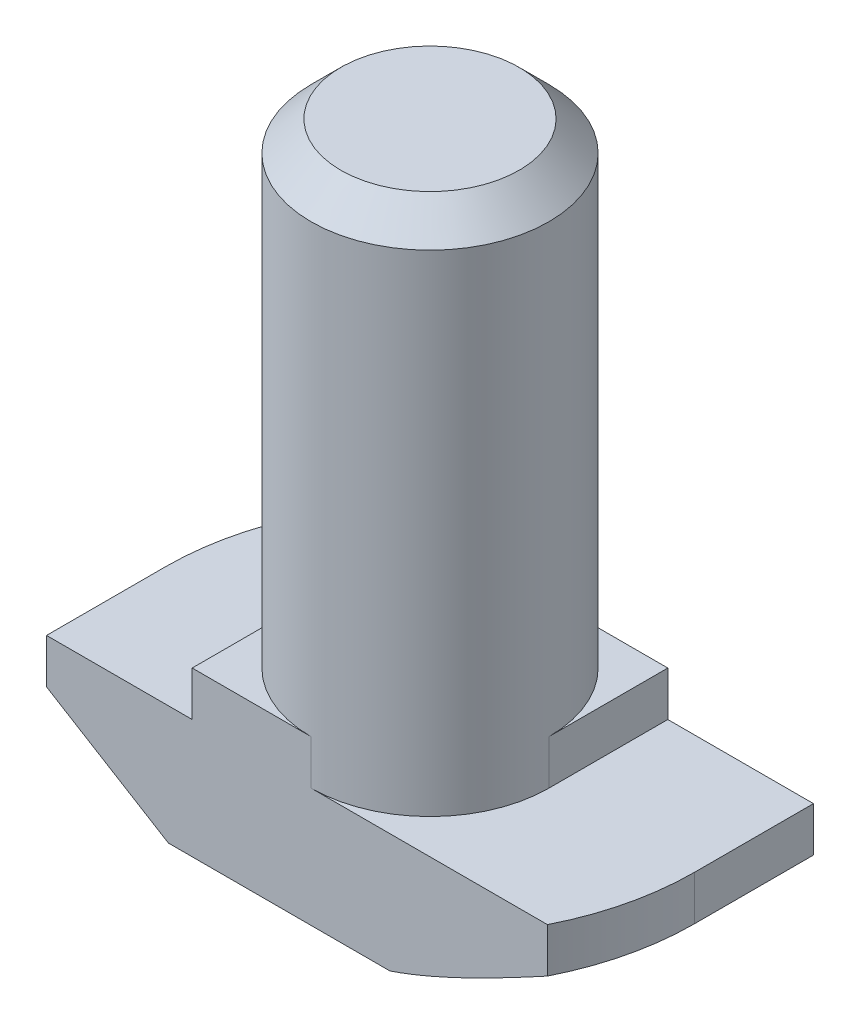
from build123d import *

# Parameters (mm, degrees)
EXTRUDE_1_DEPTH     = 4
CUT_EXTRUDE_1_DEPTH = 1.5
SKETCH_2_R          = 4
EXTRUDE_2_DEPTH     = 16
CUT_EXTRUDE_2_DEPTH = 5
CHAMFER_2_SIZE      = 1


with BuildPart() as part:
    # Эскиз1 → Бобышка-Вытянуть1 (new body, symmetric)
    with BuildSketch(Plane.XY):
        Polygon((8.9, 0), (-8.9, 0), (-8.9, 4), (-4, 4), (-4, 5.5), (4, 5.5), (4, 4), (8.9, 4), align=None)
    extrude(amount=EXTRUDE_1_DEPTH, both=True)

    # Эскиз3 → Вырез-Вытянуть1 (cut)
    with BuildSketch(Plane(origin=(0, 5.5, 0), x_dir=(1, 0, 0), z_dir=(0, 1, 0))):
        with BuildLine():
            Line((-4, 0), (-4, 4))
            Line((-4, 4), (0, 4))
            ThreePointArc((0, 4), (-2.828427125, 2.828427125), (-4, 0))
        make_face()
        with BuildLine():
            Line((0, -4), (4, -4))
            Line((4, -4), (4, 0))
            ThreePointArc((4, 0), (2.828427125, -2.828427125), (0, -4))
        make_face()
    extrude(amount=-CUT_EXTRUDE_1_DEPTH, mode=Mode.SUBTRACT)

    # Эскиз2 → Бобышка-Вытянуть2 (add)
    with BuildSketch(Plane(origin=(0, 5.5, 0), x_dir=(1, 0, 0), z_dir=(0, 1, 0))):
        with Locations(Location((0, 0, 0), (0, 0, 270))):  # turned: the seam where the file's is
            Circle(SKETCH_2_R)
    extrude(amount=EXTRUDE_2_DEPTH)

    # Эскиз4 → Вырез-Вытянуть2 (cut, through all)
    with BuildSketch(Plane(origin=(0, 4, 0), x_dir=(1, 0, 0), z_dir=(0, 1, 0))):
        with BuildLine():
            Line((-7.950471684, 4), (-8.9, 4))
            Line((-8.9, 4), (-8.9, 0))
            ThreePointArc((-8.9, 0), (-8.659364815, 2.055578022), (-7.950471684, 4))
        make_face()
        with BuildLine():
            Line((7.950471684, -4), (8.9, -4))
            Line((8.9, -4), (8.9, 0))
            ThreePointArc((8.9, 0), (8.659364815, -2.055578022), (7.950471684, -4))
        make_face()
    extrude(amount=-CUT_EXTRUDE_2_DEPTH, mode=Mode.SUBTRACT)

    # Вырез-По траектории1: sweep along a path in Эскиз6
    with BuildLine(Plane.XZ) as sweep_1_path:
        Line((0, -8.9), (8.9, -8.9))
        Line((8.9, -8.9), (8.9, 0))
        ThreePointArc((8.9, 0), (6.293250353, 6.293250353), (0, 8.9))
        Line((0, 8.9), (-8.9, 8.9))
        Line((-8.9, 8.9), (-8.9, 0))
        ThreePointArc((-8.9, 0), (-6.293250353, -6.293250353), (0, -8.9))
    # Эскиз5 → Вырез-По траектории1 (sweep, cut)
    with BuildSketch(Plane.XY.offset(4)):
        Polygon((-8.9, 2.5), (-4.8, 0), (-8.9, 0), align=None)
    sweep(path=sweep_1_path.line, transition=Transition.RIGHT, mode=Mode.SUBTRACT)

    # Фаска2
    chamfer_2_edges = [part.edges().sort_by_distance(p)[0] for p in [
        (0, 21.5, -4),
    ]]
    chamfer(chamfer_2_edges, length=CHAMFER_2_SIZE)


solid = part.part
